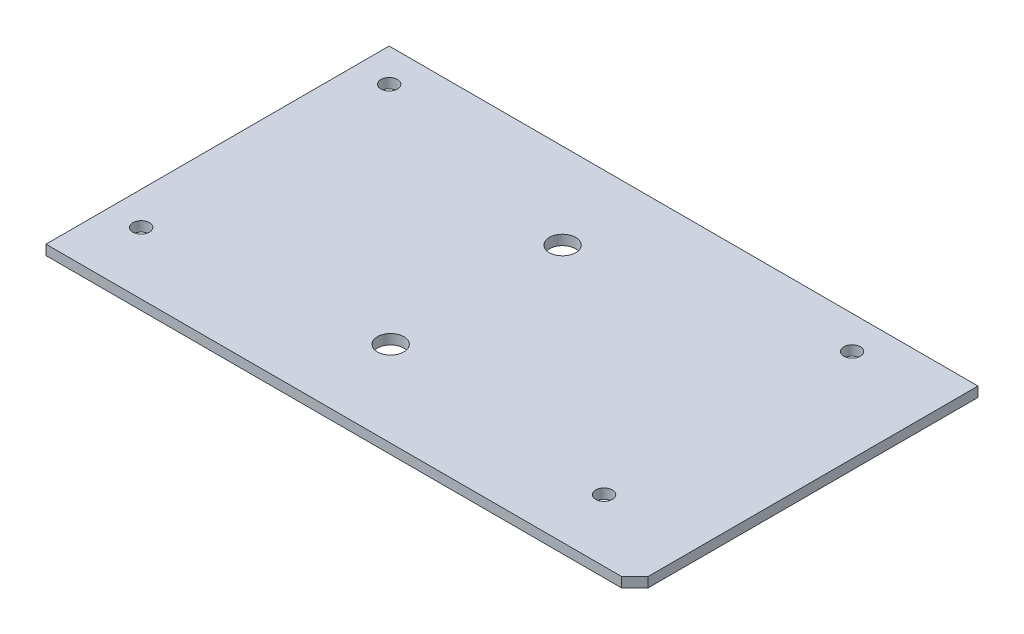
from build123d import *

# Parameters (mm, degrees)
SKETCH2_R           = 2.5
BOSS_EXTRUDE1_DEPTH = 3
CUT_EXTRUDE1_DEPTH  = 4
SKETCH4_R           = 4
CUT_EXTRUDE2_DEPTH  = 5


with BuildPart() as part:
    # Sketch2 → Boss-Extrude1 (new body)
    with BuildSketch(Plane(origin=(0, 0, 0), x_dir=(1, 0, 0), z_dir=(0, 1, 0))):
        Polygon((-80, -37.5), (-80, -56.28), (98.09, -56.28), (98.09, 47.5), (-80, 47.5), align=None)
        with Locations((-70, -37.5)):
            Circle(SKETCH2_R, mode=Mode.SUBTRACT)
        with Locations((-70, 37.5)):
            Circle(SKETCH2_R, mode=Mode.SUBTRACT)
        with Locations((70, 37.5)):
            Circle(SKETCH2_R, mode=Mode.SUBTRACT)
        with Locations((70, -37.5)):
            Circle(SKETCH2_R, mode=Mode.SUBTRACT)
    extrude(amount=BOSS_EXTRUDE1_DEPTH)

    # Sketch3 → Cut-Extrude1 (cut, through all)
    with BuildSketch(Plane(origin=(0, 3, 0), x_dir=(1, 0, 0), z_dir=(0, 1, 0))):
        Polygon((98.09, -56.28), (94.09, -56.28), (98.09, -52.28), align=None)
    extrude(amount=-CUT_EXTRUDE1_DEPTH, mode=Mode.SUBTRACT)

    # Sketch4 → Cut-Extrude2 (cut)
    with BuildSketch(Plane(origin=(0, 3, 0), x_dir=(1, 0, 0), z_dir=(0, 1, 0))):
        with Locations((-1.66, 21.61)):
            Circle(SKETCH4_R)
        with Locations((-1.66, -30.39)):
            Circle(SKETCH4_R)
    extrude(amount=-CUT_EXTRUDE2_DEPTH, mode=Mode.SUBTRACT)


solid = part.part
